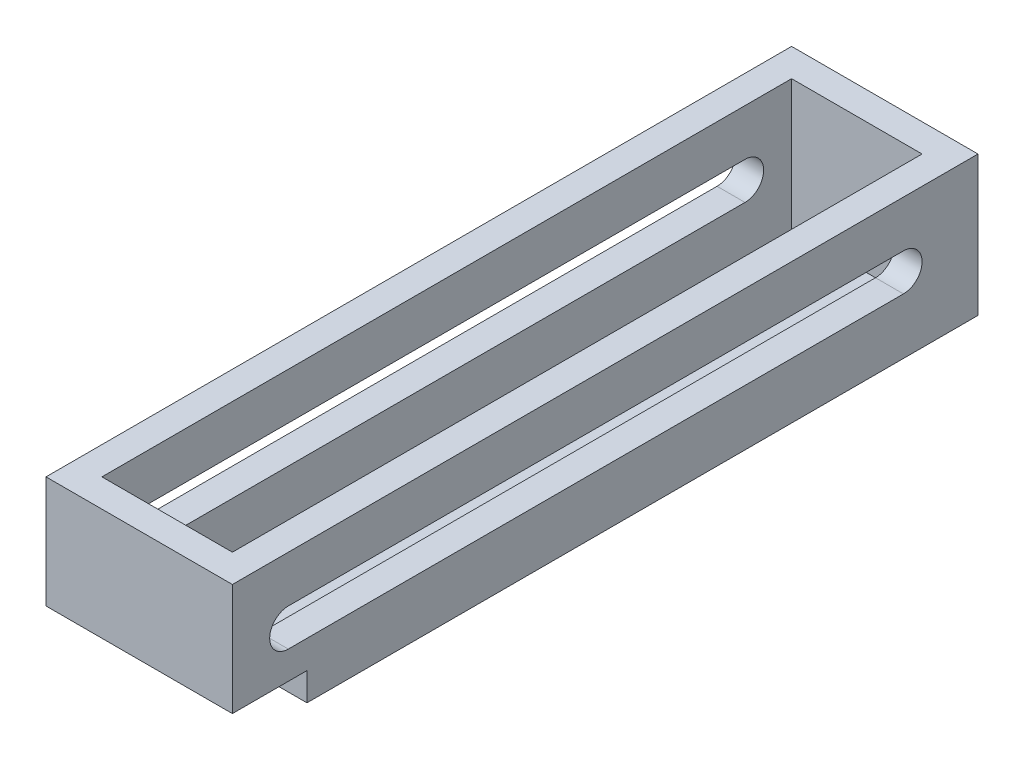
from build123d import *

# Parameters (mm, degrees)
SKETCH1_W           = 127
SKETCH1_H           = 508
BOSS_EXTRUDE1_DEPTH = 95.25
SKETCH2_W           = 88.9
SKETCH2_H           = 469.9
CUT_EXTRUDE2_DEPTH  = 88.9
CUT_EXTRUDE3_DEPTH  = 128
SKETCH4_W           = 127
SKETCH4_H           = 19.05
CUT_EXTRUDE4_DEPTH  = 50.8


with BuildPart() as part:
    # Sketch1 → Boss-Extrude1 (new body)
    with BuildSketch(Plane(origin=(0, 0, 0), x_dir=(1, 0, 0), z_dir=(0, 1, 0))):
        Rectangle(SKETCH1_W, SKETCH1_H)
    extrude(amount=BOSS_EXTRUDE1_DEPTH)

    # Sketch2 → Cut-Extrude2 (cut)
    with BuildSketch(Plane(origin=(0, 95.25, 0), x_dir=(1, 0, 0), z_dir=(0, 1, 0))):
        Rectangle(SKETCH2_W, SKETCH2_H)
    extrude(amount=-CUT_EXTRUDE2_DEPTH, mode=Mode.SUBTRACT)

    # Sketch3 → Cut-Extrude3 (cut, through all)
    with BuildSketch(Plane(origin=(63.5, 0, 0), x_dir=(0, 0, -1), z_dir=(1, 0, 0))):
        with BuildLine():
            Line((203.2, 38.1), (-215.9, 38.1))
            ThreePointArc((-215.9, 38.1), (-228.6, 50.8), (-215.9, 63.5))
            Line((-215.9, 63.5), (203.2, 63.5))
            ThreePointArc((203.2, 63.5), (215.9, 50.8), (203.2, 38.1))
        make_face()
    extrude(amount=-CUT_EXTRUDE3_DEPTH, mode=Mode.SUBTRACT)

    # Sketch4 → Cut-Extrude4 (cut)
    with BuildSketch(Plane.XY.offset(254)):
        with Locations((0, 9.525)):
            Rectangle(SKETCH4_W, SKETCH4_H)
    extrude(amount=-CUT_EXTRUDE4_DEPTH, mode=Mode.SUBTRACT)


solid = part.part
